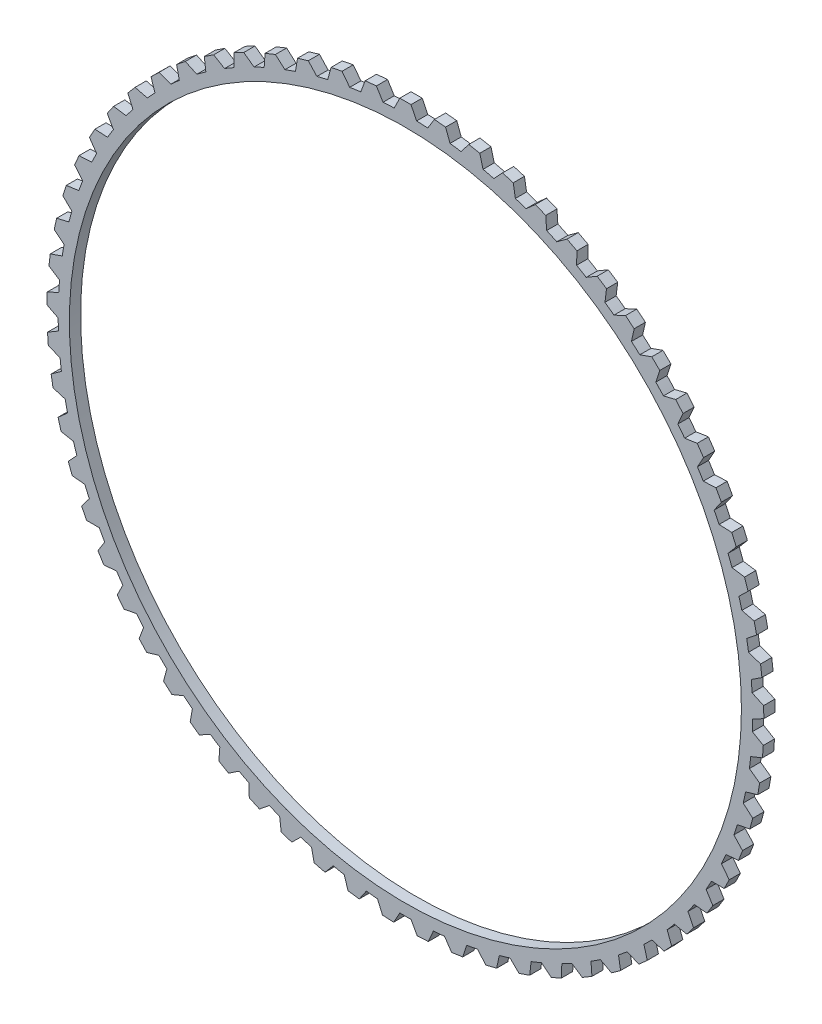
from build123d import *

# Parameters (mm, degrees)
SKETCH1_R           = 300
BOSS_EXTRUDE4_DEPTH = 10


with BuildPart() as part:
    # Sketch1 → Boss-Extrude4 (new body)
    with BuildSketch(Plane.XY):
        with BuildLine():
            Line((-5, 320), (5, 320))
            Line((5, 320), (9.998699187, 309.838709677))
            ThreePointArc((9.998699187, 309.838709677), (14.977147653, 309.637990318), (19.951727115, 309.357283065))
            Line((19.951727115, 309.357283065), (25.907796519, 318.988692714))
            Line((25.907796519, 318.988692714), (35.861112866, 318.023553505))
            Line((35.861112866, 318.023553505), (39.855770329, 307.427255739))
            ThreePointArc((39.855770329, 307.427255739), (44.791605366, 306.74698383), (49.715869517, 305.987470852))
            Line((49.715869517, 305.987470852), (56.573698922, 314.999073951))
            Line((56.573698922, 314.999073951), (66.387400184, 313.077806778))
            Line((66.387400184, 313.077806778), (69.340718882, 302.145436346))
            ThreePointArc((69.340718882, 302.145436346), (74.187855929, 300.991963402), (79.01582824, 299.760736067))
            Line((79.01582824, 299.760736067), (86.711387942, 308.068393707))
            Line((86.711387942, 308.068393707), (96.293846233, 305.208936923))
            Line((96.293846233, 305.208936923), (98.178251825, 294.042566423))
            ThreePointArc((98.178251825, 294.042566423), (102.89143447, 292.42666211), (107.578037465, 290.735216056))
            Line((107.578037465, 290.735216056), (116.039476095, 298.261361875))
            Line((116.039476095, 298.261361875), (125.301222585, 294.490413458))
            Line((125.301222585, 294.490413458), (126.099120884, 283.194300282))
            ThreePointArc((126.099120884, 283.194300282), (130.634343409, 281.131051864), (135.135819539, 278.995179667))
            Line((135.135819539, 278.995179667), (144.284134926, 285.669544069))
            Line((144.284134926, 285.669544069), (153.138695182, 281.022312349))
            Line((153.138695182, 281.022312349), (152.842636427, 269.701925262))
            ThreePointArc((152.842636427, 269.701925262), (157.157554682, 267.210596733), (161.431874877, 264.650240457))
            Line((161.431874877, 264.650240457), (171.181651663, 270.4105067))
            Line((171.181651663, 270.4105067), (179.546353044, 264.930381626))
            Line((179.546353044, 264.930381626), (178.159101455, 253.691416033))
            ThreePointArc((178.159101455, 253.691416033), (182.213428211, 250.795268256), (186.220684294, 247.834333257))
            Line((186.220684294, 247.834333257), (196.480891442, 252.626719288))
            Line((196.480891442, 252.626719288), (204.277634983, 246.364867313))
            Line((204.277634983, 246.364867313), (201.812142954, 235.312258406))
            ThreePointArc((201.812142954, 235.312258406), (205.568024055, 232.038331933), (209.270801357, 228.704463663))
            Line((209.270801357, 228.704463663), (219.945642076, 232.484224264))
            Line((219.945642076, 232.484224264), (227.101631683, 225.499110612))
            Line((227.101631683, 225.499110612), (223.580918851, 214.736053624))
            ThreePointArc((223.580918851, 214.736053624), (227.003286645, 211.114916224), (230.367013332, 207.439242113))
            Line((230.367013332, 207.439242113), (241.356819511, 210.171086678))
            Line((241.356819511, 210.171086678), (247.805241638, 202.527929473))
            Line((247.805241638, 202.527929473), (243.262179948, 192.154916166))
            ThreePointArc((243.262179948, 192.154916166), (246.319080711, 188.220377424), (249.312350573, 184.237216251))
            Line((249.312350573, 184.237216251), (260.514513352, 185.895638283))
            Line((260.514513352, 185.895638283), (266.19516082, 177.665799625))
            Line((266.19516082, 177.665799625), (260.672167615, 167.77968003))
            ThreePointArc((260.672167615, 167.77968003), (263.335059888, 163.568475673), (265.929925569, 159.315017141))
            Line((265.929925569, 159.315017141), (277.239853374, 159.884532401))
            Line((277.239853374, 159.884532401), (282.099687507, 151.144852075))
            Line((282.099687507, 151.144852075), (275.648329487, 141.837930226))
            ThreePointArc((275.648329487, 141.837930226), (277.892350562, 137.389379136), (280.064584502, 132.905336641))
            Line((280.064584502, 132.905336641), (291.376679583, 132.380627718))
            Line((291.376679583, 132.380627718), (295.370325419, 123.212705764))
            Line((295.370325419, 123.212705764), (288.050837176, 114.571877885))
            ThreePointArc((288.050837176, 114.571877885), (289.855035232, 109.927514983), (291.584355869, 105.254754822))
            Line((291.584355869, 105.254754822), (302.793000243, 103.640720781))
            Line((302.793000243, 103.640720781), (305.883170186, 94.130155619))
            Line((305.883170186, 94.130155619), (297.76389181, 86.236098789))
            ThreePointArc((297.76389181, 86.236098789), (299.111421537, 81.439287242), (300.381682668, 76.621437716))
            Line((300.381682668, 76.621437716), (311.382224242, 73.93314836))
            Line((311.382224242, 73.93314836), (313.540066209, 64.168737572))
            Line((313.540066209, 64.168737572), (304.696805213, 57.095156474))
            ThreePointArc((304.696805213, 57.095156474), (305.575085089, 52.190682818), (306.374426629, 47.272726891))
            Line((306.374426629, 47.272726891), (317.06415631, 43.535282052))
            Line((317.06415631, 43.535282052), (318.269523113, 33.608193311))
            Line((318.269523113, 33.608193311), (308.784846643, 27.421132067))
            ThreePointArc((308.784846643, 27.421132067), (309.185676404, 22.45478805), (309.506635117, 17.482643353))
            Line((309.506635117, 17.482643353), (319.785745779, 12.730938546))
            Line((319.785745779, 12.730938546), (320.027383232, 2.733858405))
            Line((320.027383232, 2.733858405), (309.989847157, -2.508916063))
            ThreePointArc((309.989847157, -2.508916063), (309.909484365, -7.490761023), (309.749063545, -12.470670917))
            Line((309.749063545, -12.470670917), (319.521581902, -18.192270303))
            Line((319.521581902, -18.192270303), (318.7972339, -28.1660018))
            Line((318.7972339, -28.1660018), (308.30055599, -32.415539119))
            ThreePointArc((308.30055599, -32.415539119), (307.73975097, -37.366370879), (307.099448424, -42.307549892))
            Line((307.099448424, -42.307549892), (316.274131105, -48.945622826))
            Line((316.274131105, -48.945622826), (314.590560691, -58.802883636))
            Line((314.590560691, -58.802883636), (303.732745599, -62.01950702))
            ThreePointArc((303.732745599, -62.01950702), (302.696734437, -66.893100998), (301.582528496, -71.749414673))
            Line((301.582528496, -71.749414673), (310.073713961, -79.241983257))
            Line((310.073713961, -79.241983257), (307.446640179, -88.89073879))
            Line((307.446640179, -88.89073879), (296.329064398, -91.044415495))
            ThreePointArc((296.329064398, -91.044415495), (294.827520051, -95.795268256), (293.249813757, -100.521374501))
            Line((293.249813757, -100.521374501), (300.978222095, -108.79848264))
            Line((300.978222095, -108.79848264), (297.432173224, -118.148645067))
            Line((297.432173224, -118.148645067), (286.158638565, -119.219266792))
            ThreePointArc((286.158638565, -119.219266792), (284.205580548, -123.803020905), (282.179104518, -128.354793339))
            Line((282.179104518, -128.354793339), (289.072577663, -137.339159905))
            Line((289.072577663, -137.339159905), (284.640662207, -146.303429278))
            Line((284.640662207, -146.303429278), (273.316426625, -146.280999918))
            ThreePointArc((273.316426625, -146.280999918), (270.930090114, -150.654858105), (268.47376501, -154.989798055))
            Line((268.47376501, -154.989798055), (274.467940459, -164.597538438))
            Line((274.467940459, -164.597538438), (269.191538018, -173.09221779))
            Line((269.191538018, -173.09221779), (257.922332851, -171.97694676))
            ThreePointArc((257.922332851, -171.97694676), (255.124998427, -176.100071487), (252.261758294, -180.177704787))
            Line((252.261758294, -180.177704787), (257.300670047, -190.319114103))
            Line((257.300670047, -190.319114103), (251.229044969, -198.264890901))
            Line((251.229044969, -198.264890901), (240.120087748, -196.067191187))
            ThreePointArc((240.120087748, -196.067191187), (236.937873369, -199.901085948), (233.694451509, -203.683340835))
            Line((233.694451509, -203.683340835), (237.731052605, -214.263731479))
            Line((237.731052605, -214.263731479), (230.920894017, -221.586418145))
            Line((230.920894017, -221.586418145), (220.075906082, -218.326809078))
            ThreePointArc((220.075906082, -218.326809078), (216.538523227, -221.835677831), (212.945202596, -225.287240409))
            Line((212.945202596, -225.287240409), (215.941804378, -236.207826124))
            Line((215.941804378, -236.207826124), (208.456696896, -242.839052706))
            Line((208.456696896, -242.839052706), (197.976934978, -238.547968377))
            ThreePointArc((197.976934978, -238.547968377), (194.117411237, -241.69904976), (190.207741702, -244.78769372))
            Line((190.207741702, -244.78769372), (192.136365705, -255.946511939))
            Line((192.136365705, -255.946511939), (184.046195762, -261.824364461))
            Line((184.046195762, -261.824364461), (174.029506574, -256.541869568))
            ThreePointArc((174.029506574, -256.541869568), (169.88387728, -259.305742783), (165.694362371, -262.002630289))
            Line((165.694362371, -262.002630289), (166.537001555, -273.295494133))
            Line((166.537001555, -273.295494133), (157.917304886, -278.365092671))
            Line((157.917304886, -278.365092671), (148.457211556, -272.140508445))
            ThreePointArc((148.457211556, -272.140508445), (144.064183334, -274.491367952), (139.633939423, -276.771318892))
            Line((139.633939423, -276.771318892), (139.382726291, -288.092789933))
            Line((139.382726291, -288.092789933), (130.313982683, -292.306801011))
            Line((130.313982683, -292.306801011), (121.498811554, -285.198244719))
            ThreePointArc((121.498811554, -285.198244719), (116.899400923, -287.114141177), (112.269792005, -288.955868262))
            Line((112.269792005, -288.955868262), (110.927072067, -300.200240977))
            Line((110.927072067, -300.200240977), (101.493953935, -303.519319508))
            Line((101.493953935, -303.519319508), (93.406009885, -295.593161824))
            ThreePointArc((93.406009885, -295.593161824), (88.643160304, -297.056207024), (83.857411789, -298.442514545))
            Line((83.857411789, -298.442514545), (81.435721659, -309.504803255))
            Line((81.435721659, -309.504803255), (71.726303485, -311.897959898))
            Line((71.726303485, -311.897959898), (64.441101468, -303.228205221))
            ThreePointArc((64.441101468, -303.228205221), (59.55928238, -304.224739103), (54.662077513, -305.142683481))
            Line((54.662077513, -305.142683481), (51.184027859, -315.919602576))
            Line((51.184027859, -315.919602576), (41.288963865, -317.364493072))
            Line((41.288963865, -317.364493072), (34.874523849, -308.032088566))
            ThreePointArc((34.874523849, -308.032088566), (29.919315483, -308.552806762), (24.956378147, -308.993817397))
            Line((24.956378147, -308.993817397), (20.454442582, -319.384745689))
            Line((20.454442582, -319.384745689), (10.466120314, -319.867879484))
            Line((10.466120314, -319.867879484), (4.982332198, -309.959959295))
            ThreePointArc((4.982332198, -309.959959295), (0, -310), (-4.982332198, -309.959959295))
            Line((-4.982332198, -309.959959295), (-10.466120314, -319.867879484))
            Line((-10.466120314, -319.867879484), (-20.454442582, -319.384745689))
            Line((-20.454442582, -319.384745689), (-24.956378147, -308.993817397))
            ThreePointArc((-24.956378147, -308.993817397), (-29.919315483, -308.552806762), (-34.874523849, -308.032088566))
            Line((-34.874523849, -308.032088566), (-41.288963865, -317.364493072))
            Line((-41.288963865, -317.364493072), (-51.184027859, -315.919602576))
            Line((-51.184027859, -315.919602576), (-54.662077513, -305.142683481))
            ThreePointArc((-54.662077513, -305.142683481), (-59.55928238, -304.224739103), (-64.441101468, -303.228205221))
            Line((-64.441101468, -303.228205221), (-71.726303485, -311.897959898))
            Line((-71.726303485, -311.897959898), (-81.435721659, -309.504803255))
            Line((-81.435721659, -309.504803255), (-83.857411789, -298.442514545))
            ThreePointArc((-83.857411789, -298.442514545), (-88.643160304, -297.056207024), (-93.406009885, -295.593161824))
            Line((-93.406009885, -295.593161824), (-101.493953935, -303.519319508))
            Line((-101.493953935, -303.519319508), (-110.927072067, -300.200240977))
            Line((-110.927072067, -300.200240977), (-112.269792005, -288.955868262))
            ThreePointArc((-112.269792005, -288.955868262), (-116.899400923, -287.114141177), (-121.498811554, -285.198244719))
            Line((-121.498811554, -285.198244719), (-130.313982683, -292.306801011))
            Line((-130.313982683, -292.306801011), (-139.382726291, -288.092789933))
            Line((-139.382726291, -288.092789933), (-139.633939423, -276.771318892))
            ThreePointArc((-139.633939423, -276.771318892), (-144.064183334, -274.491367952), (-148.457211556, -272.140508445))
            Line((-148.457211556, -272.140508445), (-157.917304886, -278.365092671))
            Line((-157.917304886, -278.365092671), (-166.537001555, -273.295494133))
            Line((-166.537001555, -273.295494133), (-165.694362371, -262.002630289))
            ThreePointArc((-165.694362371, -262.002630289), (-169.88387728, -259.305742783), (-174.029506574, -256.541869568))
            Line((-174.029506574, -256.541869568), (-184.046195762, -261.824364461))
            Line((-184.046195762, -261.824364461), (-192.136365705, -255.946511939))
            Line((-192.136365705, -255.946511939), (-190.207741702, -244.78769372))
            ThreePointArc((-190.207741702, -244.78769372), (-194.117411237, -241.69904976), (-197.976934978, -238.547968377))
            Line((-197.976934978, -238.547968377), (-208.456696896, -242.839052706))
            Line((-208.456696896, -242.839052706), (-215.941804378, -236.207826124))
            Line((-215.941804378, -236.207826124), (-212.945202596, -225.287240409))
            ThreePointArc((-212.945202596, -225.287240409), (-216.538523227, -221.835677831), (-220.075906082, -218.326809078))
            Line((-220.075906082, -218.326809078), (-230.920894017, -221.586418145))
            Line((-230.920894017, -221.586418145), (-237.731052605, -214.263731479))
            Line((-237.731052605, -214.263731479), (-233.694451509, -203.683340835))
            ThreePointArc((-233.694451509, -203.683340835), (-236.937873369, -199.901085948), (-240.120087748, -196.067191187))
            Line((-240.120087748, -196.067191187), (-251.229044969, -198.264890901))
            Line((-251.229044969, -198.264890901), (-257.300670047, -190.319114103))
            Line((-257.300670047, -190.319114103), (-252.261758294, -180.177704787))
            ThreePointArc((-252.261758294, -180.177704787), (-255.124998427, -176.100071487), (-257.922332851, -171.97694676))
            Line((-257.922332851, -171.97694676), (-269.191538018, -173.09221779))
            Line((-269.191538018, -173.09221779), (-274.467940459, -164.597538438))
            Line((-274.467940459, -164.597538438), (-268.47376501, -154.989798055))
            ThreePointArc((-268.47376501, -154.989798055), (-270.930090114, -150.654858105), (-273.316426625, -146.280999918))
            Line((-273.316426625, -146.280999918), (-284.640662207, -146.303429278))
            Line((-284.640662207, -146.303429278), (-289.072577663, -137.339159905))
            Line((-289.072577663, -137.339159905), (-282.179104518, -128.354793339))
            ThreePointArc((-282.179104518, -128.354793339), (-284.205580548, -123.803020905), (-286.158638565, -119.219266792))
            Line((-286.158638565, -119.219266792), (-297.432173224, -118.148645067))
            Line((-297.432173224, -118.148645067), (-300.978222095, -108.79848264))
            Line((-300.978222095, -108.79848264), (-293.249813757, -100.521374501))
            ThreePointArc((-293.249813757, -100.521374501), (-294.827520051, -95.795268256), (-296.329064398, -91.044415495))
            Line((-296.329064398, -91.044415495), (-307.446640179, -88.89073879))
            Line((-307.446640179, -88.89073879), (-310.073713961, -79.241983257))
            Line((-310.073713961, -79.241983257), (-301.582528496, -71.749414673))
            ThreePointArc((-301.582528496, -71.749414673), (-302.696734437, -66.893100998), (-303.732745599, -62.01950702))
            Line((-303.732745599, -62.01950702), (-314.590560691, -58.802883636))
            Line((-314.590560691, -58.802883636), (-316.274131105, -48.945622826))
            Line((-316.274131105, -48.945622826), (-307.099448424, -42.307549892))
            ThreePointArc((-307.099448424, -42.307549892), (-307.73975097, -37.366370879), (-308.30055599, -32.415539119))
            Line((-308.30055599, -32.415539119), (-318.7972339, -28.1660018))
            Line((-318.7972339, -28.1660018), (-319.521581902, -18.192270303))
            Line((-319.521581902, -18.192270303), (-309.749063545, -12.470670917))
            ThreePointArc((-309.749063545, -12.470670917), (-309.909484365, -7.490761023), (-309.989847157, -2.508916063))
            Line((-309.989847157, -2.508916063), (-320.027383232, 2.733858405))
            Line((-320.027383232, 2.733858405), (-319.785745779, 12.730938546))
            Line((-319.785745779, 12.730938546), (-309.506635117, 17.482643353))
            ThreePointArc((-309.506635117, 17.482643353), (-309.185676404, 22.45478805), (-308.784846643, 27.421132067))
            Line((-308.784846643, 27.421132067), (-318.269523113, 33.608193311))
            Line((-318.269523113, 33.608193311), (-317.06415631, 43.535282052))
            Line((-317.06415631, 43.535282052), (-306.374426629, 47.272726891))
            ThreePointArc((-306.374426629, 47.272726891), (-305.575085089, 52.190682818), (-304.696805213, 57.095156474))
            Line((-304.696805213, 57.095156474), (-313.540066209, 64.168737572))
            Line((-313.540066209, 64.168737572), (-311.382224242, 73.93314836))
            Line((-311.382224242, 73.93314836), (-300.381682668, 76.621437716))
            ThreePointArc((-300.381682668, 76.621437716), (-299.111421537, 81.439287242), (-297.76389181, 86.236098789))
            Line((-297.76389181, 86.236098789), (-305.883170186, 94.130155619))
            Line((-305.883170186, 94.130155619), (-302.793000243, 103.640720781))
            Line((-302.793000243, 103.640720781), (-291.584355869, 105.254754822))
            ThreePointArc((-291.584355869, 105.254754822), (-289.855035232, 109.927514983), (-288.050837176, 114.571877885))
            Line((-288.050837176, 114.571877885), (-295.370325419, 123.212705764))
            Line((-295.370325419, 123.212705764), (-291.376679583, 132.380627718))
            Line((-291.376679583, 132.380627718), (-280.064584502, 132.905336641))
            ThreePointArc((-280.064584502, 132.905336641), (-277.892350562, 137.389379136), (-275.648329487, 141.837930226))
            Line((-275.648329487, 141.837930226), (-282.099687507, 151.144852075))
            Line((-282.099687507, 151.144852075), (-277.239853374, 159.884532401))
            Line((-277.239853374, 159.884532401), (-265.929925569, 159.315017141))
            ThreePointArc((-265.929925569, 159.315017141), (-263.335059888, 163.568475673), (-260.672167615, 167.77968003))
            Line((-260.672167615, 167.77968003), (-266.19516082, 177.665799625))
            Line((-266.19516082, 177.665799625), (-260.514513352, 185.895638283))
            Line((-260.514513352, 185.895638283), (-249.312350573, 184.237216251))
            ThreePointArc((-249.312350573, 184.237216251), (-246.319080711, 188.220377424), (-243.262179948, 192.154916166))
            Line((-243.262179948, 192.154916166), (-247.805241638, 202.527929473))
            Line((-247.805241638, 202.527929473), (-241.356819511, 210.171086678))
            Line((-241.356819511, 210.171086678), (-230.367013332, 207.439242113))
            ThreePointArc((-230.367013332, 207.439242113), (-227.003286645, 211.114916224), (-223.580918851, 214.736053624))
            Line((-223.580918851, 214.736053624), (-227.101631683, 225.499110612))
            Line((-227.101631683, 225.499110612), (-219.945642076, 232.484224264))
            Line((-219.945642076, 232.484224264), (-209.270801357, 228.704463663))
            ThreePointArc((-209.270801357, 228.704463663), (-205.568024055, 232.038331933), (-201.812142954, 235.312258406))
            Line((-201.812142954, 235.312258406), (-204.277634983, 246.364867313))
            Line((-204.277634983, 246.364867313), (-196.480891442, 252.626719288))
            Line((-196.480891442, 252.626719288), (-186.220684294, 247.834333257))
            ThreePointArc((-186.220684294, 247.834333257), (-182.213428211, 250.795268256), (-178.159101455, 253.691416033))
            Line((-178.159101455, 253.691416033), (-179.546353044, 264.930381626))
            Line((-179.546353044, 264.930381626), (-171.181651663, 270.4105067))
            Line((-171.181651663, 270.4105067), (-161.431874877, 264.650240457))
            ThreePointArc((-161.431874877, 264.650240457), (-157.157554682, 267.210596733), (-152.842636427, 269.701925262))
            Line((-152.842636427, 269.701925262), (-153.138695182, 281.022312349))
            Line((-153.138695182, 281.022312349), (-144.284134926, 285.669544069))
            Line((-144.284134926, 285.669544069), (-135.135819539, 278.995179667))
            ThreePointArc((-135.135819539, 278.995179667), (-130.634343409, 281.131051864), (-126.099120884, 283.194300282))
            Line((-126.099120884, 283.194300282), (-125.301222585, 294.490413458))
            Line((-125.301222585, 294.490413458), (-116.039476095, 298.261361875))
            Line((-116.039476095, 298.261361875), (-107.578037465, 290.735216056))
            ThreePointArc((-107.578037465, 290.735216056), (-102.89143447, 292.42666211), (-98.178251825, 294.042566423))
            Line((-98.178251825, 294.042566423), (-96.293846233, 305.208936923))
            Line((-96.293846233, 305.208936923), (-86.711387942, 308.068393707))
            Line((-86.711387942, 308.068393707), (-79.01582824, 299.760736067))
            ThreePointArc((-79.01582824, 299.760736067), (-74.187855929, 300.991963402), (-69.340718882, 302.145436346))
            Line((-69.340718882, 302.145436346), (-66.387400184, 313.077806778))
            Line((-66.387400184, 313.077806778), (-56.573698922, 314.999073951))
            Line((-56.573698922, 314.999073951), (-49.715869517, 305.987470852))
            ThreePointArc((-49.715869517, 305.987470852), (-44.791605366, 306.74698383), (-39.855770329, 307.427255739))
            Line((-39.855770329, 307.427255739), (-35.861112866, 318.023553505))
            Line((-35.861112866, 318.023553505), (-25.907796519, 318.988692714))
            Line((-25.907796519, 318.988692714), (-19.951727115, 309.357283065))
            ThreePointArc((-19.951727115, 309.357283065), (-14.977147653, 309.637990318), (-9.998699187, 309.838709677))
            Line((-9.998699187, 309.838709677), (-5, 320))
        make_face()
        Circle(SKETCH1_R, mode=Mode.SUBTRACT)
    extrude(amount=BOSS_EXTRUDE4_DEPTH)


solid = part.part
